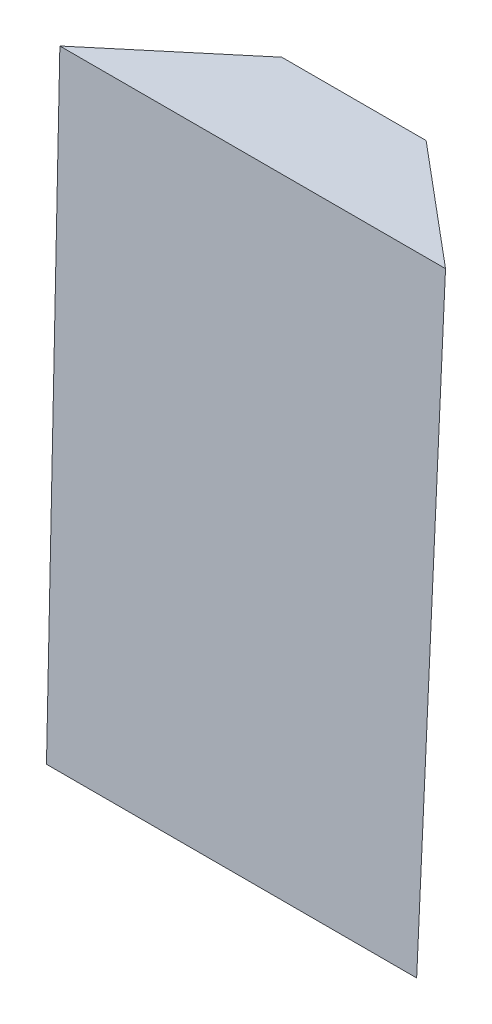
from build123d import *


with BuildPart() as part:
    # Croquis2 → Recubrir1 section 0
    with BuildSketch(Plane(origin=(0, 75, 0), x_dir=(1, 0, 0), z_dir=(0, 1, 0))):
        Polygon((13.928573894, 15.12), (31.748573894, 15.12), (46.643573894, 2.62), (-0.966426106, 2.62), align=None)
    # Croquis1 → Recubrir1 section 1
    with BuildSketch(Plane(origin=(0, 0, 0), x_dir=(1, 0, 0), z_dir=(0, 1, 0))):
        Polygon((0, 0), (45.7, 0), (30.798573894, 12.5), (14.888573894, 12.5), align=None)
    loft()


solid = part.part
